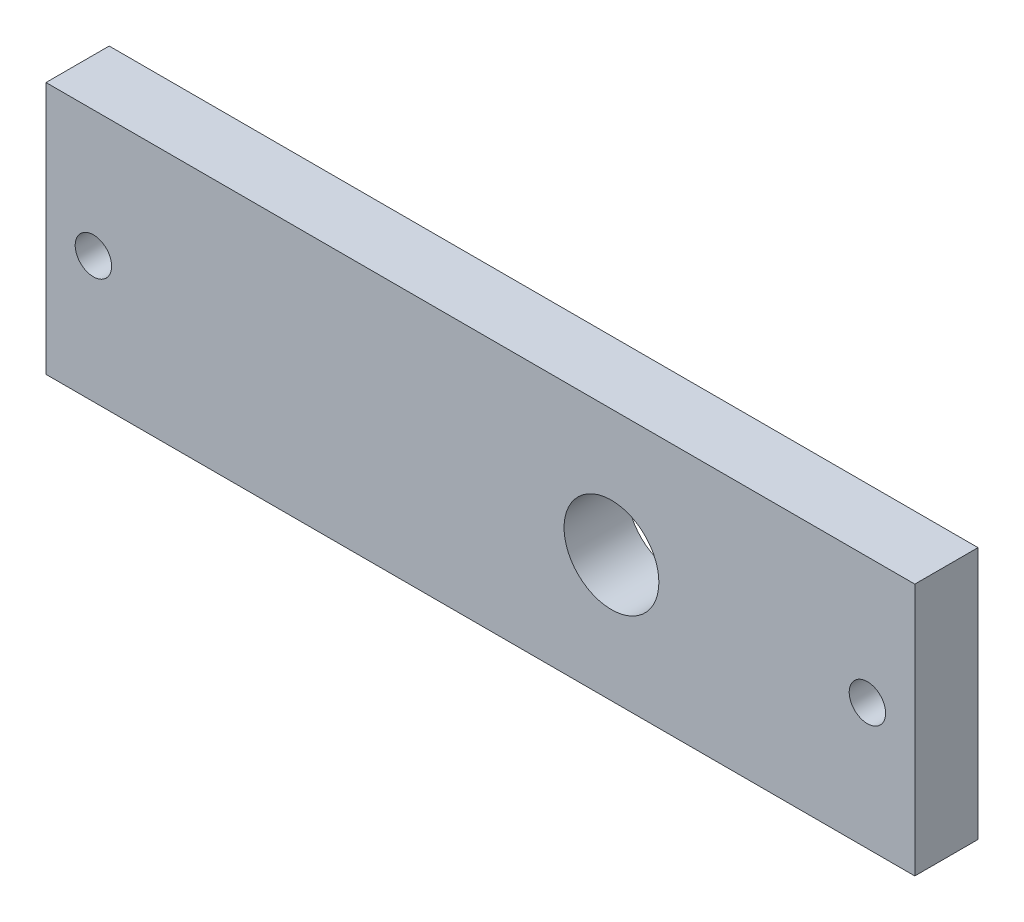
from build123d import *

# Parameters (mm, degrees)
SKETCH1_W             = 87.3
SKETCH1_H             = 25.4
SKETCH1_R             = 4.7625
BOSS_EXTRUDE1_DEPTH   = 3.175
F_6_CLEARANCE_HOLE1_D = 3.6576


with BuildPart() as part:
    # Sketch1 → Boss-Extrude1 (new, symmetric)
    with BuildSketch(Plane.XY):
        with Locations((0, 12.7)):
            Rectangle(SKETCH1_W, SKETCH1_H)
        with Locations((13.17, 12.7)):
            Circle(SKETCH1_R, mode=Mode.SUBTRACT)
    extrude(amount=BOSS_EXTRUDE1_DEPTH, both=True)

    # 6 Clearance Hole1 (through all)
    with Locations(Plane.XY.offset(3.175)):
        with Locations((-38.8875, 12.7), (38.8875, 12.7)):
            Hole(F_6_CLEARANCE_HOLE1_D / 2)


solid = part.part
